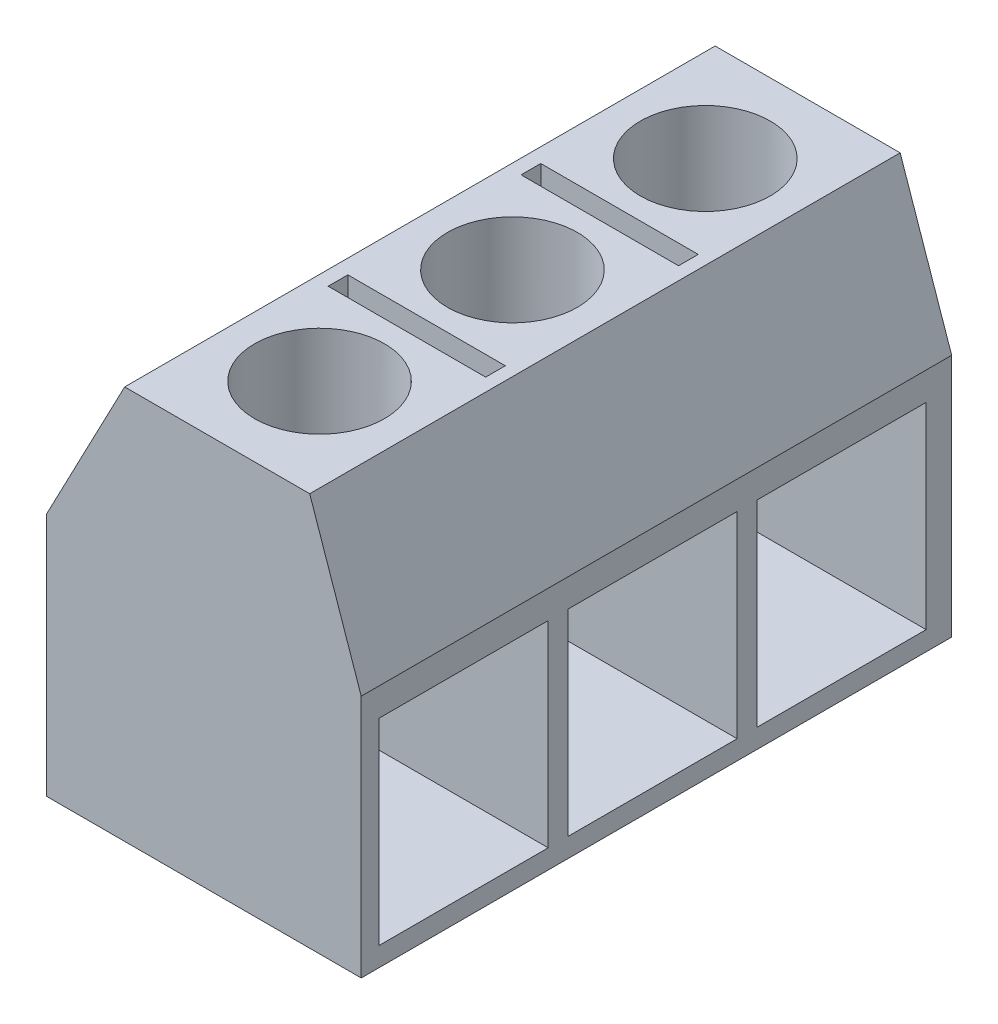
from build123d import *

# Parameters (mm, degrees)
BOSS_EXTRUDE1_DEPTH = 15
SKETCH2_W           = 4
SKETCH2_H           = 0.5
SKETCH2_R           = 1.65
CUT_EXTRUDE1_DEPTH  = 9.2
SKETCH3_W           = 4.3
SKETCH3_H           = 5
CUT_EXTRUDE2_DEPTH  = 5.8


with BuildPart() as part:
    # Sketch1 → Boss-Extrude1 (new body)
    with BuildSketch(Plane.XY):
        Polygon((-363.835743374, 0), (-355.835743374, 0), (-355.835743374, 6.2), (-357.144738603, 10), (-361.844738603, 10), (-363.835743374, 6.2), align=None)
    extrude(amount=BOSS_EXTRUDE1_DEPTH)

    # Sketch2 → Cut-Extrude1 (cut)
    with BuildSketch(Plane(origin=(0, 10, 0), x_dir=(1, 0, 0), z_dir=(0, 1, 0))):
        with Locations((-359.47498497, -5.05)):
            Rectangle(SKETCH2_W, SKETCH2_H)
        with Locations((-359.47498497, -9.95)):
            Rectangle(SKETCH2_W, SKETCH2_H)
        with Locations((-359.494738603, -2.6)):
            Circle(SKETCH2_R)
        with Locations((-359.494738603, -7.5)):
            Circle(SKETCH2_R)
        with Locations((-359.494738603, -12.4)):
            Circle(SKETCH2_R)
    extrude(amount=-CUT_EXTRUDE1_DEPTH, mode=Mode.SUBTRACT)

    # Sketch3 → Cut-Extrude2 (cut)
    with BuildSketch(Plane(origin=(-355.835743374, 0, 0), x_dir=(0, 0, -1), z_dir=(1, 0, 0))):
        with Locations((-12.4, 2.989005182)):
            Rectangle(SKETCH3_W, SKETCH3_H)
        with Locations((-7.6, 2.989005182)):
            Rectangle(SKETCH3_W, SKETCH3_H)
        with Locations((-2.8, 2.989005182)):
            Rectangle(SKETCH3_W, SKETCH3_H)
    extrude(amount=-CUT_EXTRUDE2_DEPTH, mode=Mode.SUBTRACT)


solid = part.part
